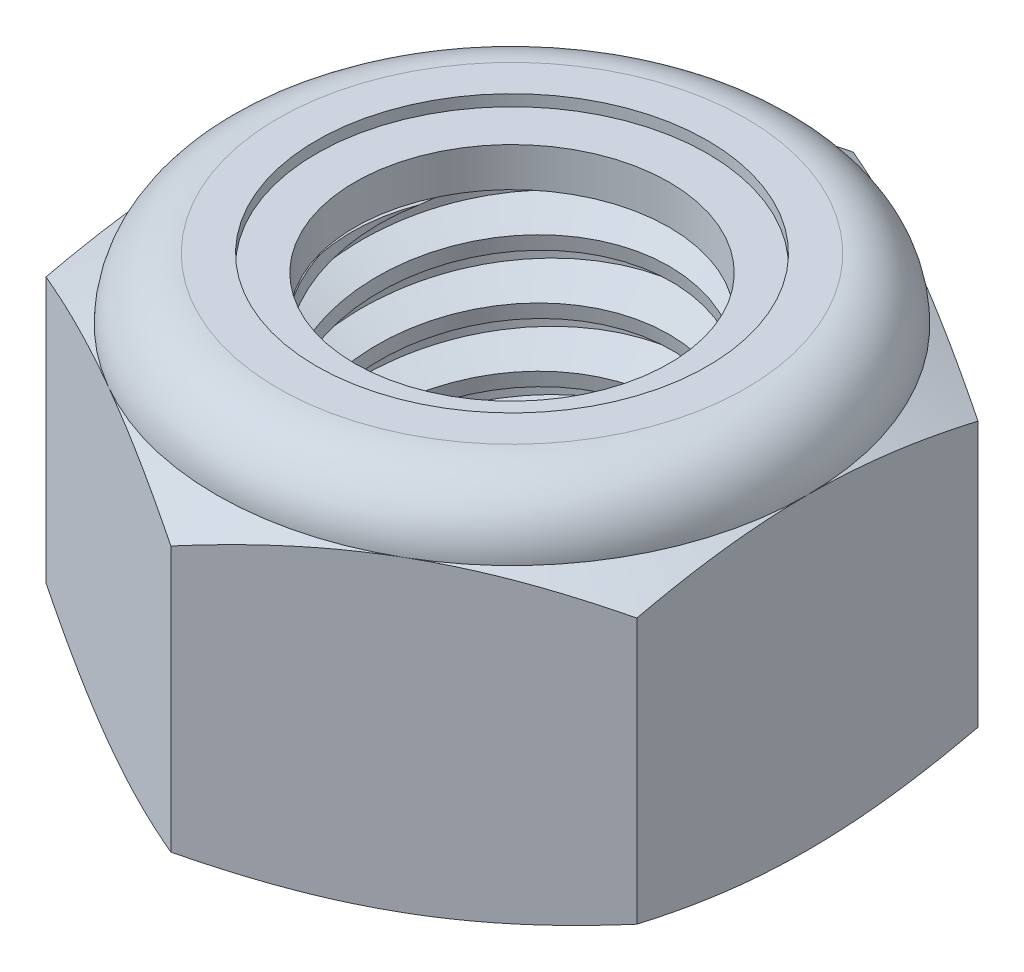
from build123d import *

# Parameters (mm, degrees)
EXTRUDE1_DEPTH      = 5
SKETCH2_W           = 2.5
SKETCH2_H           = 5
LPATTERN1_COUNT     = 6
LPATTERN1_PITCH     = 0.8
LPATTERN1_COL_COUNT = 2
LPATTERN1_COL_PITCH = 0.8


with BuildPart() as part:
    # Sketch1 → Extrude1 (new body)
    with BuildSketch(Plane(origin=(0, 0, 0), x_dir=(1, 0, 0), z_dir=(0, 1, 0))):
        Polygon((0, 4.618802154), (-4, 2.309401077), (-4, -2.309401077), (0, -4.618802154), (4, -2.309401077), (4, 2.309401077), align=None)
    extrude(amount=EXTRUDE1_DEPTH)

    # Sketch4 → Cut-Revolve2 (revolve, cut)
    with BuildSketch(Plane(origin=(0, 0, 0), x_dir=(0, 0, -1), z_dir=(1, 0, 0))):
        Polygon((0, 5), (2.5, 5), (2.127722339, 4.826404076), (2.127722339, 0.173595924), (2.5, 0), (0, 0), align=None)
    revolve(axis=Axis((0, 5, 0), (0, 1, 0)), mode=Mode.SUBTRACT)


with BuildPart() as body_2:
    # Sketch2 → Revolve1 (revolve)
    with BuildSketch(Plane(origin=(0, 0, 0), x_dir=(0, 0, -1), z_dir=(1, 0, 0))):
        with Locations((1.25, 2.5)):
            Rectangle(SKETCH2_W, SKETCH2_H)
    revolve(axis=Axis((0, -2.5, 0), (0, 1, 0)))

    # Sketch3 → Cut-Revolve1 (revolve, cut)
    with BuildSketch(Plane(origin=(0, 0, 0), x_dir=(0, 0, -1), z_dir=(1, 0, 0))):
        Polygon((2.51579905, 4.901255937), (2.626392401, 4.210047494), (2.15932044, 4.388495759), (2.127722339, 4.585983885), align=None)
    cut_revolve1 = revolve(axis=Axis((0, 5, 0.136915776), (0, -0.987440632, -0.157990501)), mode=Mode.SUBTRACT)

    # LPattern1: Cut-Revolve1 ×6
    with Locations(*[(0, -i * LPATTERN1_PITCH, 0) for i in range(1, LPATTERN1_COUNT)]):
        add(cut_revolve1, mode=Mode.SUBTRACT)

    # LPattern1 col: Cut-Revolve1 ×2
    with Locations(*[(0, i * LPATTERN1_COL_PITCH, 0) for i in range(1, LPATTERN1_COL_COUNT)]):
        add(cut_revolve1, mode=Mode.SUBTRACT)


with BuildPart() as part_1:
    add(part.part)

    # Combine1: cut body 2
    add(body_2.part, mode=Mode.SUBTRACT)

    # Sketch5 → Cut-Revolve3 (revolve, cut)
    with BuildSketch(Plane(origin=(0, 0, 0), x_dir=(0, 0, -1), z_dir=(1, 0, 0))):
        with BuildLine():
            Line((0, 0), (4, 0))
            Line((4, 0), (4.618802154, 0.288552183))
            Line((4.618802154, 0.288552183), (4.618802154, 3.878114484))
            Line((4.618802154, 3.878114484), (4, 4.166666667))
            ThreePointArc((4, 4.166666667), (3.755922318, 4.755922318), (3.166666667, 5))
            Line((3.166666667, 5), (3.166666667, 6.27))
            Line((3.166666667, 6.27), (5.888802154, 6.27))
            Line((5.888802154, 6.27), (5.888802154, -1.27))
            Line((5.888802154, -1.27), (0, -1.27))
            Line((0, -1.27), (0, 0))
        make_face()
    revolve(axis=Axis((0, 0, 0), (0, 1, 0)), mode=Mode.SUBTRACT)

    # Sketch6 → Cut-Revolve4 (revolve, cut)
    with BuildSketch(Plane(origin=(0, 0, 0), x_dir=(0, 0, -1), z_dir=(1, 0, 0))):
        with BuildLine():
            Line((0, 4.166666667), (3.8476, 4.166666667))
            ThreePointArc((3.8476, 4.166666667), (3.648159244, 4.648159244), (3.166666667, 4.8476))
            Line((3.166666667, 4.8476), (2.647194503, 4.8476))
            Line((2.647194503, 4.8476), (2.647194503, 6.27))
            Line((2.647194503, 6.27), (0, 6.27))
            Line((0, 6.27), (0, 4.166666667))
        make_face()
    revolve(axis=Axis((0, 6.27, 0), (0, 1, 0)), mode=Mode.SUBTRACT)


with BuildPart() as body_2_2:
    # Sketch7 → Revolve2 (revolve)
    with BuildSketch(Plane(origin=(0, 0, 0), x_dir=(0, 0, -1), z_dir=(1, 0, 0))):
        with BuildLine():
            Line((2.127722339, 4.242866667), (3.766579964, 4.242866667))
            ThreePointArc((3.766579964, 4.242866667), (3.566430175, 4.620419399), (3.166666667, 4.7714))
            Line((3.166666667, 4.7714), (2.127722339, 4.7714))
            Line((2.127722339, 4.7714), (2.127722339, 4.242866667))
        make_face()
    revolve(axis=Axis((0, 4.242866667, 0), (0, 1, 0)))


solid = Compound([part_1.part, body_2_2.part])
